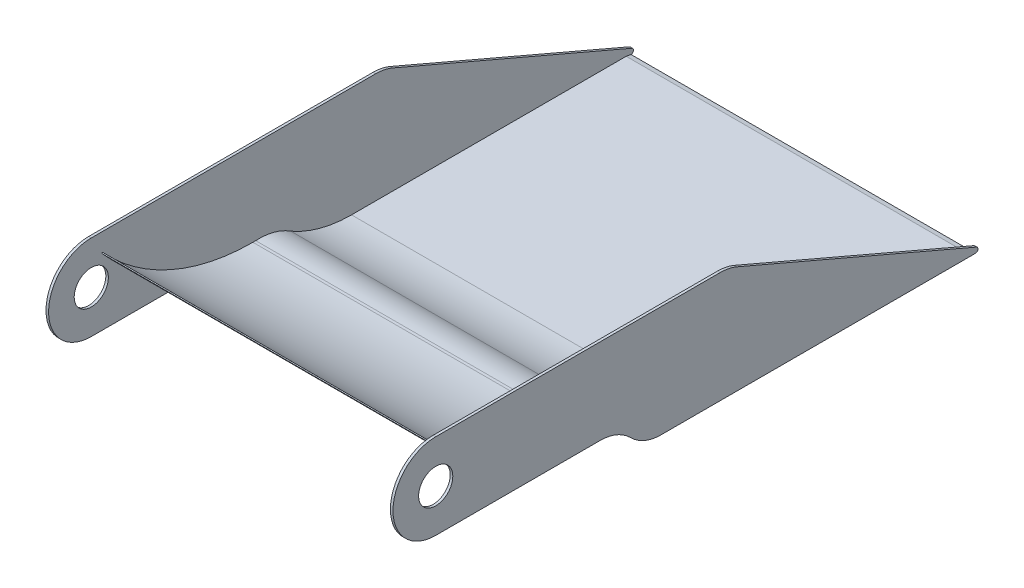
from build123d import *

# Parameters (mm, degrees)
SKETCH_1_R      = 50
SKETCH_1_R_2    = 20
EXTRUDE_1_DEPTH = 3
EXTRUDE_2_DEPTH = 400
SKETCH_3_R      = 20
EXTRUDE_3_DEPTH = 3


with BuildPart() as part:
    # 草图1 → 凸台-拉伸1 (new body)
    with BuildSketch(Plane(origin=(0, 0, 0), x_dir=(0, 0, -1), z_dir=(1, 0, 0))):
        with BuildLine():
            ThreePointArc((50, 0), (35.355339059, -35.355339059), (0, -50))
            Line((0, -50), (192.417140489, -50))
            ThreePointArc((192.417140489, -50), (211.551312107, -53.806023374), (227.772479548, -64.644660941))
            Line((227.772479548, -64.644660941), (228.405158627, -65.277340019))
            ThreePointArc((228.405158627, -65.277340019), (244.626326068, -76.115977585), (263.760497686, -79.92200096))
            Line((263.760497686, -79.92200096), (631.54077851, -79.92200096))
            ThreePointArc((631.54077851, -79.92200096), (634.479494864, -77.525280493), (632.72269013, -74.164631757))
            Line((632.72269013, -74.164631757), (352.484009, 45.956153386))
            ThreePointArc((352.484009, 45.956153386), (342.840140888, 48.978605887), (332.785482, 50))
            Line((332.785482, 50), (0, 50))
            ThreePointArc((0, 50), (35.355339059, 35.355339059), (50, 0))
        make_face()
        Circle(SKETCH_1_R)
        Circle(SKETCH_1_R_2, mode=Mode.SUBTRACT)
    extrude(amount=EXTRUDE_1_DEPTH)

    # 草图2 → 凸台-拉伸2 (add)
    with BuildSketch(Plane.ZY):
        with BuildLine():
            ThreePointArc((-233.606386859, -60.015816693), (-267.811656592, -74.11426689), (-304.494792617, -78.92200096))
            Line((-304.494792617, -78.92200096), (-625.869496691, -78.92200096))
            Line((-625.869496691, -78.92200096), (-631.54077851, -79.92200096))
            Line((-631.54077851, -79.92200096), (-263.760497686, -79.92200096))
            ThreePointArc((-263.760497686, -79.92200096), (-244.626326068, -76.115977585), (-228.405158627, -65.277340019))
            Line((-228.405158627, -65.277340019), (-227.772479548, -64.644660941))
            ThreePointArc((-227.772479548, -64.644660941), (-211.551312107, -53.806023374), (-192.417140489, -50))
            Line((-192.417140489, -50), (-170.764869856, -50))
            ThreePointArc((-170.764869856, -50), (-83.751443835, -26.590589439), (-12.213025887, 28.19619335))
            ThreePointArc((-12.213025887, 28.19619335), (-12.840107981, 28.661683678), (-13.582379077, 28.418894018))
            ThreePointArc((-13.582379077, 28.418894018), (-93.185539951, -28.785672237), (-189.104289812, -49))
            Line((-189.104289812, -49), (-192.417140489, -49))
            ThreePointArc((-192.417140489, -49), (-213.907702397, -51.157903364), (-233.606386859, -60.015816693))
        make_face()
    extrude(amount=EXTRUDE_2_DEPTH)

    # 草图3 → 凸台-拉伸3 (add)
    with BuildSketch(Plane.ZY.offset(400)):
        with BuildLine():
            Line((-352.484009, 45.956153386), (-632.72269013, -74.164631757))
            ThreePointArc((-632.72269013, -74.164631757), (-634.479494864, -77.525280493), (-631.54077851, -79.92200096))
            Line((-631.54077851, -79.92200096), (-625.869496691, -78.92200096))
            Line((-625.869496691, -78.92200096), (-304.494792617, -78.92200096))
            ThreePointArc((-304.494792617, -78.92200096), (-267.811656592, -74.11426689), (-233.606386859, -60.015816693))
            ThreePointArc((-233.606386859, -60.015816693), (-213.907702397, -51.157903364), (-192.417140489, -49))
            Line((-192.417140489, -49), (-189.104289812, -49))
            ThreePointArc((-189.104289812, -49), (-93.185539951, -28.785672237), (-13.582379077, 28.418894018))
            ThreePointArc((-13.582379077, 28.418894018), (-12.840107981, 28.661683678), (-12.213025887, 28.19619335))
            ThreePointArc((-12.213025887, 28.19619335), (-83.751443835, -26.590589439), (-170.764869856, -50))
            Line((-170.764869856, -50), (0, -50))
            ThreePointArc((0, -50), (50, 0), (0, 50))
            Line((0, 50), (-332.785482, 50))
            ThreePointArc((-332.785482, 50), (-342.840140888, 48.978605887), (-352.484009, 45.956153386))
        make_face()
        Circle(SKETCH_3_R, mode=Mode.SUBTRACT)
        with BuildLine():
            ThreePointArc((-170.764869856, -50), (-83.751443835, -26.590589439), (-12.213025887, 28.19619335))
            ThreePointArc((-12.213025887, 28.19619335), (-12.840107981, 28.661683678), (-13.582379077, 28.418894018))
            ThreePointArc((-13.582379077, 28.418894018), (-93.185539951, -28.785672237), (-189.104289812, -49))
            Line((-189.104289812, -49), (-192.417140489, -49))
            ThreePointArc((-192.417140489, -49), (-213.907702397, -51.157903364), (-233.606386859, -60.015816693))
            ThreePointArc((-233.606386859, -60.015816693), (-267.811656592, -74.11426689), (-304.494792617, -78.92200096))
            Line((-304.494792617, -78.92200096), (-625.869496691, -78.92200096))
            Line((-625.869496691, -78.92200096), (-631.54077851, -79.92200096))
            Line((-631.54077851, -79.92200096), (-263.760497686, -79.92200096))
            ThreePointArc((-263.760497686, -79.92200096), (-244.626326068, -76.115977585), (-228.405158627, -65.277340019))
            Line((-228.405158627, -65.277340019), (-227.772479548, -64.644660941))
            ThreePointArc((-227.772479548, -64.644660941), (-211.551312107, -53.806023374), (-192.417140489, -50))
            Line((-192.417140489, -50), (-170.764869856, -50))
        make_face()
    extrude(amount=EXTRUDE_3_DEPTH)


solid = part.part
